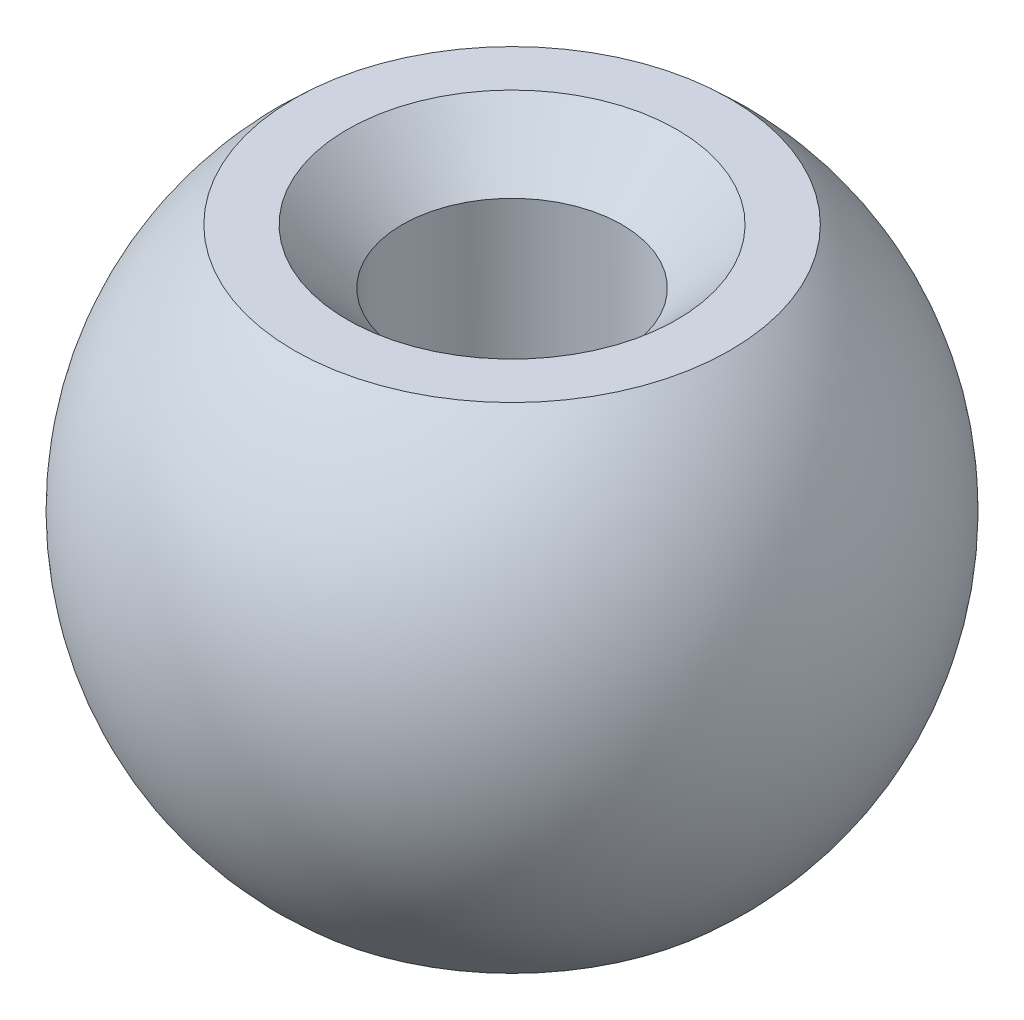
from build123d import *

# Parameters (mm, degrees)
CHAMFER1_SIZE = 1


with BuildPart() as part:
    # Sketch3 → Revolve1 (revolve)
    with BuildSketch(Plane.XY):
        with BuildLine():
            Line((2, -4.5), (3.968626967, -4.5))
            ThreePointArc((3.968626967, -4.5), (6, 0), (3.968626967, 4.5))
            Line((3.968626967, 4.5), (2, 4.5))
            Line((2, 4.5), (2, -4.5))
        make_face()
    revolve(axis=Axis((0, 5.534482641, 0), (0, -1, 0)))

    # Chamfer1
    chamfer1_edges = [part.edges().sort_by_distance(p)[0] for p in [
        (-2, 4.5, 0),
    ]]
    chamfer(chamfer1_edges, length=CHAMFER1_SIZE)


solid = part.part
